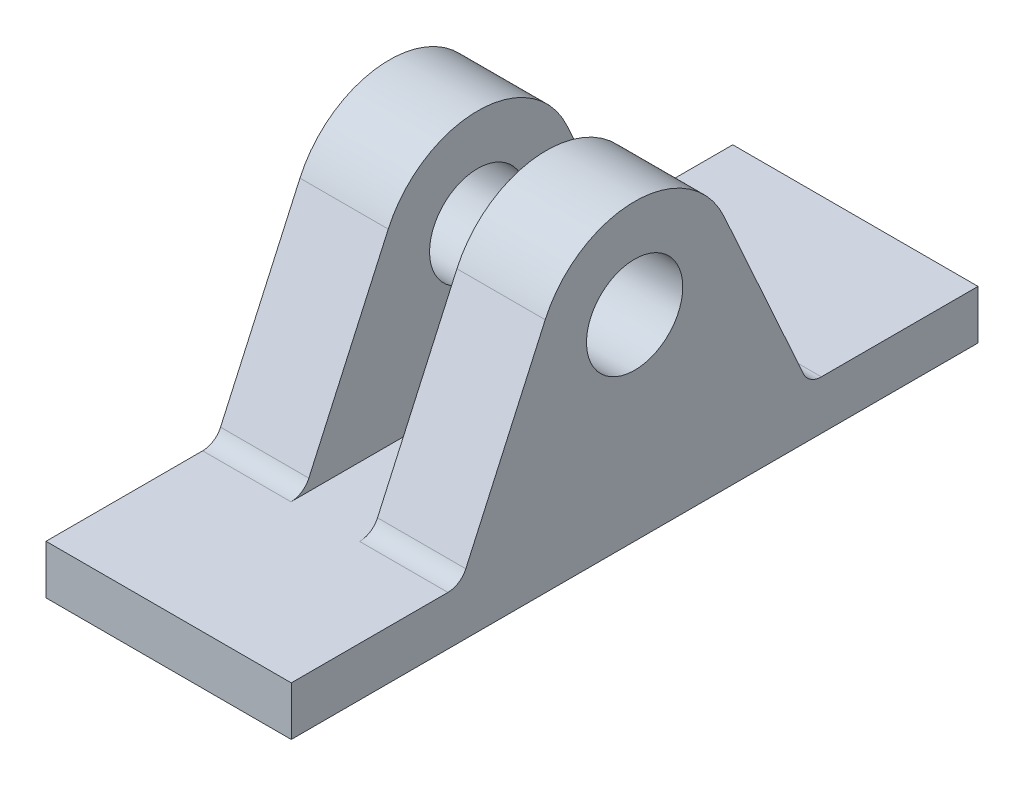
from build123d import *

# Parameters (mm, degrees)
SKETCH1_R           = 6.22935
BOSS_EXTRUDE1_DEPTH = 31.75
SKETCH2_W           = 8.89
SKETCH2_H           = 31.75
CUT_EXTRUDE1_DEPTH  = 89.9


with BuildPart() as part:
    # Sketch1 → Boss-Extrude1 (new body)
    with BuildSketch(Plane(origin=(0, 0, 0), x_dir=(0, 0, -1), z_dir=(1, 0, 0))):
        with BuildLine():
            Line((22.594948, 7.845241626), (32.874076775, 30.623791868))
            ThreePointArc((32.874076775, 30.623791868), (44.45, 38.1), (56.025923225, 30.623791868))
            Line((56.025923225, 30.623791868), (66.305052, 7.845241626))
            ThreePointArc((66.305052, 7.845241626), (67.242210206, 6.756307629), (68.620236645, 6.35))
            Line((68.620236645, 6.35), (88.9, 6.35))
            Line((88.9, 6.35), (88.9, 0))
            Line((88.9, 0), (0, 0))
            Line((0, 0), (0, 6.35))
            Line((0, 6.35), (20.279763355, 6.35))
            ThreePointArc((20.279763355, 6.35), (21.657789794, 6.756307629), (22.594948, 7.845241626))
        make_face()
        with Locations((44.45, 25.4)):
            Circle(SKETCH1_R, mode=Mode.SUBTRACT)
    extrude(amount=-BOSS_EXTRUDE1_DEPTH)

    # Sketch2 → Cut-Extrude1 (cut, through all)
    with BuildSketch(Plane.XY):
        with Locations((-15.875, 22.225)):
            Rectangle(SKETCH2_W, SKETCH2_H)
    extrude(amount=-CUT_EXTRUDE1_DEPTH, mode=Mode.SUBTRACT)


solid = part.part
